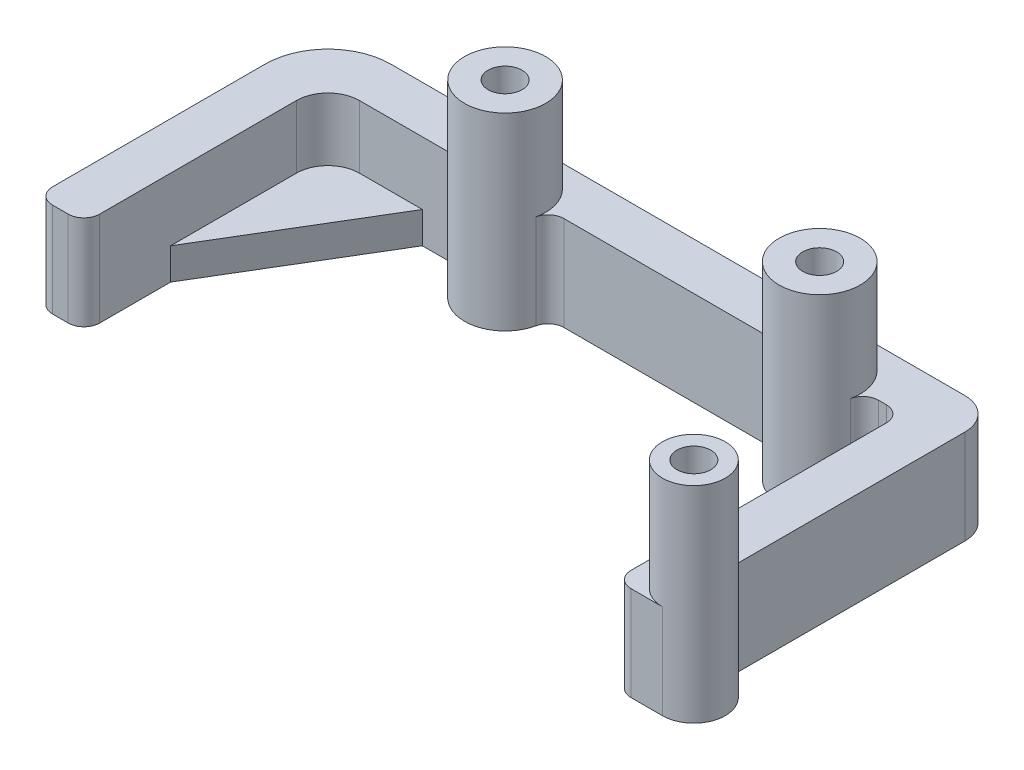
from build123d import *

# Parameters (mm, degrees)
SKETCH2_R           = 3.429
BOSS_EXTRUDE1_DEPTH = 19.05
BOSS_EXTRUDE2_START = 19.05
SKETCH3_R           = 8.1915
SKETCH3_R_2         = 3.429
SKETCH3_R_3         = 6.35
BOSS_EXTRUDE2_DEPTH = 19.05
BOSS_EXTRUDE5_START = 3.429
SKETCH4_R           = 6.35
SKETCH4_R_2         = 3.429
BOSS_EXTRUDE5_DEPTH = 3.429
BOSS_EXTRUDE6_START = -19.05
BOSS_EXTRUDE6_DEPTH = 6.35


with BuildPart() as part:
    # Sketch2 → Boss-Extrude1 (new body)
    with BuildSketch(Plane(origin=(0, 0, 0), x_dir=(1, 0, 0), z_dir=(0, 1, 0))):
        with BuildLine():
            Line((-84.142567987, -15.875), (-42.857432013, -15.875))
            ThreePointArc((-42.857432013, -15.875), (-40.864863591, -16.578098691), (-39.754797373, -18.375994594))
            ThreePointArc((-39.754797373, -18.375994594), (-31.75, -24.828560646), (-23.745202627, -18.375994594))
            ThreePointArc((-23.745202627, -18.375994594), (-22.635136409, -16.578098691), (-20.642567987, -15.875))
            Line((-20.642567987, -15.875), (-19.05, -15.875))
            ThreePointArc((-19.05, -15.875), (-16.80493597, -16.80493597), (-15.875, -19.05))
            Line((-15.875, -19.05), (-15.875, -70.612060646))
            ThreePointArc((-15.875, -70.612060646), (-14.94506403, -72.857124676), (-12.7, -73.787060646))
            Line((-12.7, -73.787060646), (-6.35, -73.787060646))
            ThreePointArc((-6.35, -73.787060646), (-0.091449146, -68.510858211), (-4.233333333, -61.450223232))
            ThreePointArc((-4.233333333, -61.450223232), (-5.767376644, -60.28989163), (-6.35, -58.456804525))
            Line((-6.35, -58.456804525), (-6.35, -12.7))
            ThreePointArc((-6.35, -12.7), (-8.209871939, -8.209871939), (-12.7, -6.35))
            Line((-12.7, -6.35), (-128.5875, -6.35))
            ThreePointArc((-128.5875, -6.35), (-137.567756121, -10.069743879), (-141.2875, -19.05))
            Line((-141.2875, -19.05), (-141.2875, -61.948583794))
            ThreePointArc((-141.2875, -61.948583794), (-140.35756403, -64.193647824), (-138.1125, -65.123583794))
            Line((-138.1125, -65.123583794), (-134.9375, -65.123583794))
            ThreePointArc((-134.9375, -65.123583794), (-132.69243597, -64.193647824), (-131.7625, -61.948583794))
            Line((-131.7625, -61.948583794), (-131.7625, -22.225))
            ThreePointArc((-131.7625, -22.225), (-129.90262806, -17.734871939), (-125.4125, -15.875))
            Line((-125.4125, -15.875), (-106.357432013, -15.875))
            ThreePointArc((-106.357432013, -15.875), (-104.364863591, -16.578098691), (-103.254797373, -18.375994594))
            ThreePointArc((-103.254797373, -18.375994594), (-95.25, -24.828560646), (-87.245202627, -18.375994594))
            ThreePointArc((-87.245202627, -18.375994594), (-86.135136409, -16.578098691), (-84.142567987, -15.875))
        make_face()
        with Locations(Location((-95.25, -16.637060646, 0), (0, 0, 270))):
            Circle(SKETCH2_R, mode=Mode.SUBTRACT)
        with Locations(Location((-31.75, -16.637060646, 0), (0, 0, 270))):
            Circle(SKETCH2_R, mode=Mode.SUBTRACT)
        with Locations(Location((-6.35, -67.437060646, 0), (0, 0, 270))):
            Circle(SKETCH2_R, mode=Mode.SUBTRACT)
    extrude(amount=-BOSS_EXTRUDE1_DEPTH)

    # Sketch3 → Boss-Extrude2 (add)
    # profile 1 of 3: a face of its own
    with BuildSketch(Plane(origin=(0, 0, 0), x_dir=(1, 0, 0), z_dir=(0, 1, 0)).offset(BOSS_EXTRUDE2_START)):
        with Locations(Location((-95.25, -16.637060646, 0), (0, 0, 270))):
            Circle(SKETCH3_R)
        with Locations(Location((-95.25, -16.637060646, 0), (0, 0, 270))):
            Circle(SKETCH3_R_2, mode=Mode.SUBTRACT)
    # profile 2 of 3: a face of its own
    with BuildSketch(Plane(origin=(0, 0, 0), x_dir=(1, 0, 0), z_dir=(0, 1, 0)).offset(BOSS_EXTRUDE2_START)):
        with Locations(Location((-31.75, -16.637060646, 0), (0, 0, 270))):
            Circle(SKETCH3_R)
        with Locations(Location((-31.75, -16.637060646, 0), (0, 0, 270))):
            Circle(SKETCH3_R_2, mode=Mode.SUBTRACT)
    # profile 3 of 3: a face of its own
    with BuildSketch(Plane(origin=(0, 0, 0), x_dir=(1, 0, 0), z_dir=(0, 1, 0)).offset(BOSS_EXTRUDE2_START)):
        with Locations(Location((-6.35, -67.437060646, 0), (0, 0, 270))):
            Circle(SKETCH3_R_3)
        with Locations(Location((-6.35, -67.437060646, 0), (0, 0, 270))):
            Circle(SKETCH3_R_2, mode=Mode.SUBTRACT)
    extrude(amount=-BOSS_EXTRUDE2_DEPTH)

    # Sketch4 → Boss-Extrude5 (add)
    with BuildSketch(Plane(origin=(0, 19.05, 0), x_dir=(1, 0, 0), z_dir=(0, 1, 0)).offset(BOSS_EXTRUDE5_START)):
        with Locations(Location((-6.35, -67.437060646, 0), (0, 0, 270))):
            Circle(SKETCH4_R)
        with Locations(Location((-6.35, -67.437060646, 0), (0, 0, 270))):
            Circle(SKETCH4_R_2, mode=Mode.SUBTRACT)
    extrude(amount=-BOSS_EXTRUDE5_DEPTH)

    # Sketch6 → Boss-Extrude6 (add)
    with BuildSketch(Plane(origin=(0, 0, 0), x_dir=(1, 0, 0), z_dir=(0, 1, 0)).offset(BOSS_EXTRUDE6_START)):
        Polygon((-112.7125, -15.875), (-131.7625, -47.625), (-131.7625, -15.875), align=None)
    extrude(amount=BOSS_EXTRUDE6_DEPTH)


solid = part.part
